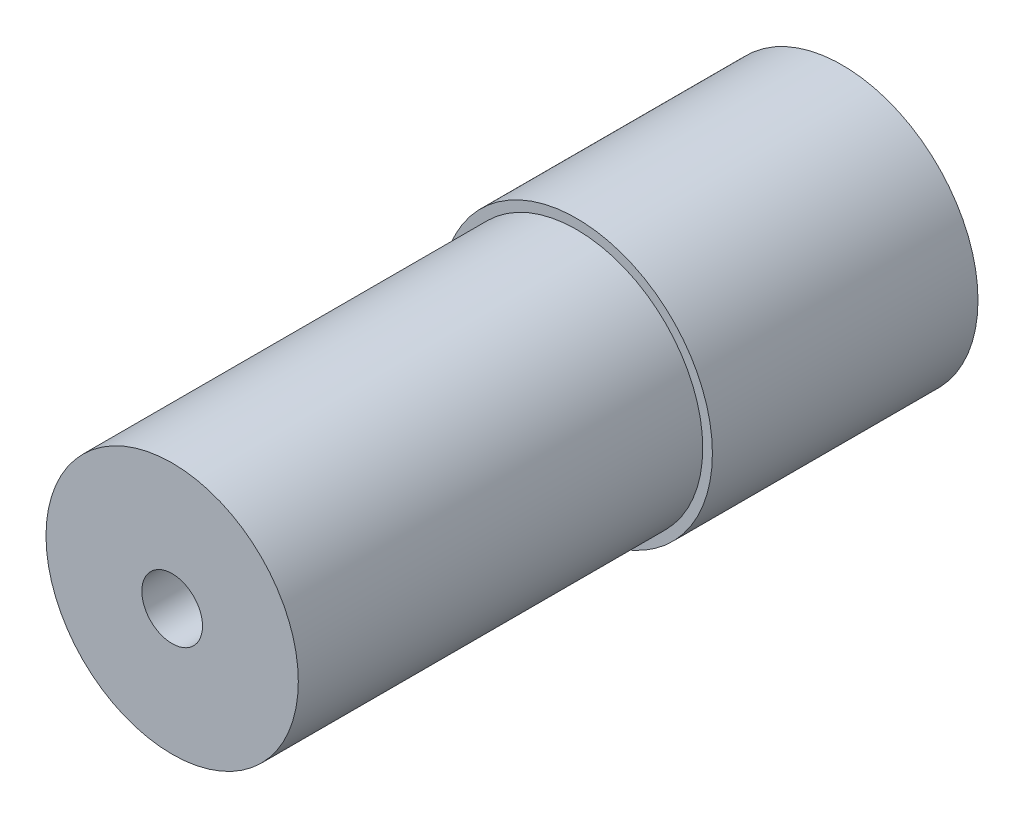
from build123d import *

# Parameters (mm, degrees)
SKETCH1_R           = 22.5
SKETCH1_R_2         = 20.9
BOSS_EXTRUDE1_DEPTH = 44
SKETCH1_2_R         = 20.9
BOSS_EXTRUDE2_DEPTH = 111
SKETCH3_R           = 5.025
CUT_EXTRUDE1_DEPTH  = 171
SKETCH2_R           = 13
BOSS_EXTRUDE5_DEPTH = 2
SKETCH2_4_R         = 5
CUT_EXTRUDE2_DEPTH  = 35
SKETCH6_R           = 1.5
CUT_EXTRUDE4_DEPTH  = 10
SKETCH6_3_R         = 1.5
CUT_EXTRUDE5_DEPTH  = 10
SKETCH6_4_R         = 1.5
CUT_EXTRUDE6_DEPTH  = 10
SKETCH6_5_R         = 1.5
CUT_EXTRUDE7_DEPTH  = 10
SKETCH6_7_R         = 4.5
CUT_EXTRUDE8_DEPTH  = 4
SKETCH6_8_R         = 4.5
CUT_EXTRUDE9_DEPTH  = 4
SKETCH6_9_R         = 4.5
CUT_EXTRUDE10_DEPTH = 4
SKETCH6_10_R        = 4.5
CUT_EXTRUDE11_DEPTH = 4


with BuildPart() as part:
    # Sketch1 → Boss-Extrude1 (new body)
    with BuildSketch(Plane.XY):
        Circle(SKETCH1_R)
        Circle(SKETCH1_R_2, mode=Mode.SUBTRACT)
    extrude(amount=BOSS_EXTRUDE1_DEPTH)

    # Sketch1_2 → Boss-Extrude2 (add)
    with BuildSketch(Plane.XY):
        Circle(SKETCH1_2_R)
    extrude(amount=BOSS_EXTRUDE2_DEPTH)

    # Sketch3 → Cut-Extrude1 (cut)
    with BuildSketch(Plane(origin=(0, 0, 0), x_dir=(-1, 0, 0), z_dir=(0, 0, -1))):
        Circle(SKETCH3_R)
    extrude(amount=-CUT_EXTRUDE1_DEPTH, mode=Mode.SUBTRACT)

    # Sketch2 → Boss-Extrude5 (add)
    with BuildSketch(Plane(origin=(0, 0, 0), x_dir=(-1, 0, 0), z_dir=(0, 0, -1))):
        Circle(SKETCH2_R)
    extrude(amount=BOSS_EXTRUDE5_DEPTH)

    # Sketch2_4 → Cut-Extrude2 (cut)
    with BuildSketch(Plane(origin=(0, 0, 0), x_dir=(-1, 0, 0), z_dir=(0, 0, -1))):
        Circle(SKETCH2_4_R)
    extrude(amount=CUT_EXTRUDE2_DEPTH, mode=Mode.SUBTRACT)

    # Sketch6 → Cut-Extrude4 (cut)
    with BuildSketch(Plane(origin=(0, 0, -2), x_dir=(-1, 0, 0), z_dir=(0, 0, -1))):
        with Locations((0, 17.5)):
            Circle(SKETCH6_R)
    extrude(amount=-CUT_EXTRUDE4_DEPTH, mode=Mode.SUBTRACT)

    # Sketch6_3 → Cut-Extrude5 (cut)
    with BuildSketch(Plane(origin=(0, 0, -2), x_dir=(-1, 0, 0), z_dir=(0, 0, -1))):
        with Locations((17.5, 0)):
            Circle(SKETCH6_3_R)
    extrude(amount=-CUT_EXTRUDE5_DEPTH, mode=Mode.SUBTRACT)

    # Sketch6_4 → Cut-Extrude6 (cut)
    with BuildSketch(Plane(origin=(0, 0, -2), x_dir=(-1, 0, 0), z_dir=(0, 0, -1))):
        with Locations((0, -17.5)):
            Circle(SKETCH6_4_R)
    extrude(amount=-CUT_EXTRUDE6_DEPTH, mode=Mode.SUBTRACT)

    # Sketch6_5 → Cut-Extrude7 (cut)
    with BuildSketch(Plane(origin=(0, 0, -2), x_dir=(-1, 0, 0), z_dir=(0, 0, -1))):
        with Locations((-17.5, 0)):
            Circle(SKETCH6_5_R)
    extrude(amount=-CUT_EXTRUDE7_DEPTH, mode=Mode.SUBTRACT)

    # Sketch6_7 → Cut-Extrude8 (cut)
    with BuildSketch(Plane(origin=(0, 0, -2), x_dir=(-1, 0, 0), z_dir=(0, 0, -1))):
        with Locations((12.374368671, 12.374368671)):
            Circle(SKETCH6_7_R)
    extrude(amount=-CUT_EXTRUDE8_DEPTH, mode=Mode.SUBTRACT)

    # Sketch6_8 → Cut-Extrude9 (cut)
    with BuildSketch(Plane(origin=(0, 0, -2), x_dir=(-1, 0, 0), z_dir=(0, 0, -1))):
        with Locations((-12.374368671, 12.374368671)):
            Circle(SKETCH6_8_R)
    extrude(amount=-CUT_EXTRUDE9_DEPTH, mode=Mode.SUBTRACT)

    # Sketch6_9 → Cut-Extrude10 (cut)
    with BuildSketch(Plane(origin=(0, 0, -2), x_dir=(-1, 0, 0), z_dir=(0, 0, -1))):
        with Locations((-12.374368671, -12.374368671)):
            Circle(SKETCH6_9_R)
    extrude(amount=-CUT_EXTRUDE10_DEPTH, mode=Mode.SUBTRACT)

    # Sketch6_10 → Cut-Extrude11 (cut)
    with BuildSketch(Plane(origin=(0, 0, -2), x_dir=(-1, 0, 0), z_dir=(0, 0, -1))):
        with Locations((12.374368671, -12.374368671)):
            Circle(SKETCH6_10_R)
    extrude(amount=-CUT_EXTRUDE11_DEPTH, mode=Mode.SUBTRACT)


solid = part.part
